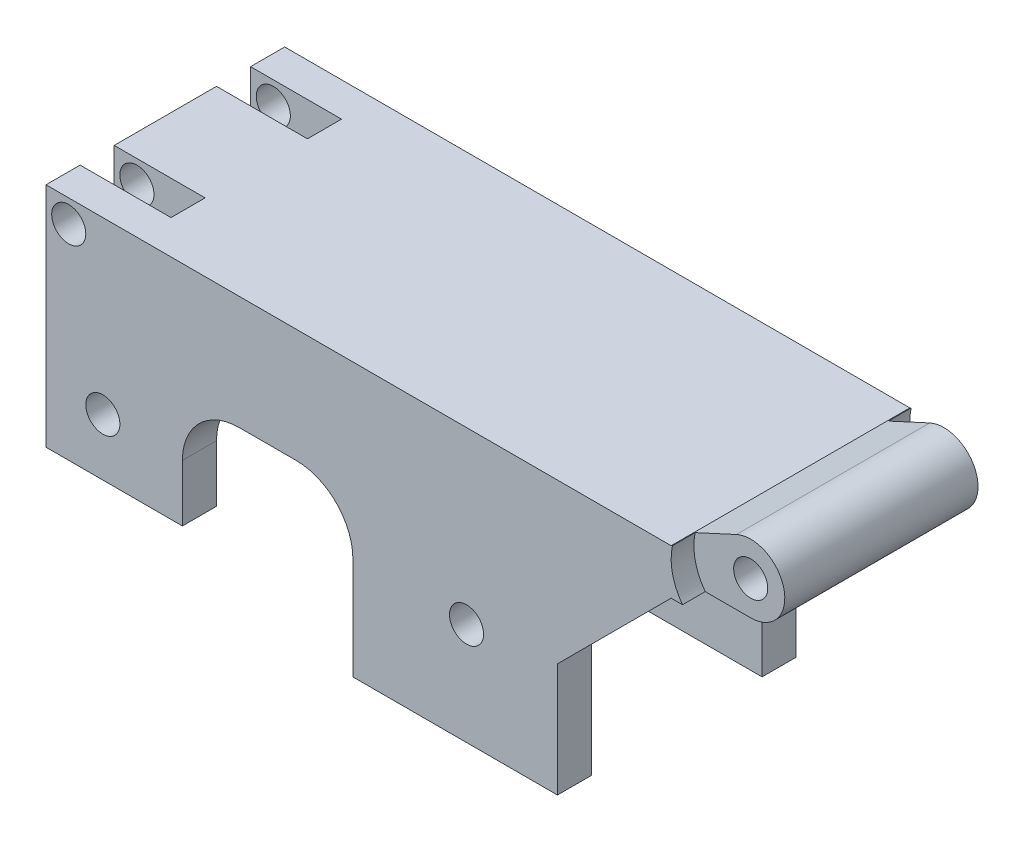
from build123d import *

# Parameters (mm, degrees)
SKETCH_1_R          = 3
SKETCH_1_R_2        = 1.5
EXTRUDE_1_DEPTH     = 25
EXTRUDE_2_DEPTH     = 5
SKETCH_3_R          = 1.5
CUT_EXTRUDE_1_DEPTH = 26
SKETCH_4_R          = 5
CUT_EXTRUDE_2_DEPTH = 4
SKETCH_5_R          = 1.5
EXTRUDE_3_DEPTH     = 5
SKETCH_6_R          = 5
CUT_EXTRUDE_3_DEPTH = 4
SKETCH_7_W          = 8
SKETCH_7_H          = 3
CUT_EXTRUDE_4_DEPTH = 25
SKETCH_8_R          = 1.5
CUT_EXTRUDE_5_DEPTH = 26
SKETCH_9_W          = 62.045271576
SKETCH_9_H          = 47.186533399
CUT_EXTRUDE_6_DEPTH = 2
SKETCH_10_R         = 43.321303534
CUT_EXTRUDE_7_DEPTH = 2


with BuildPart() as part:
    # 草图1 → 凸台-拉伸1 (new body)
    with BuildSketch(Plane.XY):
        with BuildLine():
            Line((-60, -3), (0, -3))
            ThreePointArc((0, -3), (-2.93041003, -0.642415018), (-1.255026274, 2.72486863))
            Line((-1.255026274, 2.72486863), (-5, 1))
            Line((-5, 1), (-60, 1))
            Line((-60, 1), (-60, -3))
        make_face()
        Circle(SKETCH_1_R)
        Circle(SKETCH_1_R_2, mode=Mode.SUBTRACT)
    extrude(amount=EXTRUDE_1_DEPTH)

    # 草图2 → 凸台-拉伸2 (add)
    with BuildSketch(Plane.XY.offset(25)):
        with BuildLine():
            Line((-60, -3), (-60, -19))
            Line((-60, -19), (-48, -19))
            Line((-48, -19), (-48, -14))
            ThreePointArc((-48, -14), (-46.535533906, -10.464466094), (-43, -9))
            Line((-43, -9), (-38, -9))
            ThreePointArc((-38, -9), (-34.464466094, -10.464466094), (-33, -14))
            Line((-33, -14), (-33, -23))
            Line((-33, -23), (-15, -23))
            Line((-15, -23), (-15, -13))
            Line((-15, -13), (-5, -3))
            Line((-5, -3), (-60, -3))
        make_face()
    extrude(amount=-EXTRUDE_2_DEPTH)

    # 草图3 → 切除-拉伸1 (cut, through all)
    with BuildSketch(Plane.XY.offset(25)):
        with Locations((-55, -14)):
            Circle(SKETCH_3_R)
        with Locations((-23, -14)):
            Circle(SKETCH_3_R)
    extrude(amount=-CUT_EXTRUDE_1_DEPTH, mode=Mode.SUBTRACT)

    # 草图4 → 切除-拉伸2 (cut)
    with BuildSketch(Plane.XY.offset(25)):
        Circle(SKETCH_4_R)
    extrude(amount=-CUT_EXTRUDE_2_DEPTH, mode=Mode.SUBTRACT)

    # 草图5 → 凸台-拉伸3 (add)
    with BuildSketch(Plane(origin=(0, 0, 0), x_dir=(-1, 0, 0), z_dir=(0, 0, -1))):
        with BuildLine():
            Line((60, -3), (5, -3))
            Line((5, -3), (15, -13))
            Line((15, -13), (15, -23))
            Line((15, -23), (33, -23))
            Line((33, -23), (33, -14))
            ThreePointArc((33, -14), (34.464466094, -10.464466094), (38, -9))
            Line((38, -9), (43, -9))
            ThreePointArc((43, -9), (46.535533906, -10.464466094), (48, -14))
            Line((48, -14), (48, -19))
            Line((48, -19), (60, -19))
            Line((60, -19), (60, -3))
        make_face()
        with Locations((23, -14)):
            Circle(SKETCH_5_R, mode=Mode.SUBTRACT)
        with Locations((55, -14)):
            Circle(SKETCH_5_R, mode=Mode.SUBTRACT)
    extrude(amount=-EXTRUDE_3_DEPTH)

    # 草图6 → 切除-拉伸3 (cut)
    with BuildSketch(Plane(origin=(0, 0, 0), x_dir=(-1, 0, 0), z_dir=(0, 0, -1))):
        Circle(SKETCH_6_R)
    extrude(amount=-CUT_EXTRUDE_3_DEPTH, mode=Mode.SUBTRACT)

    # 草图7 → 切除-拉伸4 (cut, through all)
    with BuildSketch(Plane(origin=(0, 1, 0), x_dir=(1, 0, 0), z_dir=(0, 1, 0))):
        with Locations((-56, -6.5)):
            Rectangle(SKETCH_7_W, SKETCH_7_H)
        with Locations((-56, -18.5)):
            Rectangle(SKETCH_7_W, SKETCH_7_H)
    extrude(amount=-CUT_EXTRUDE_4_DEPTH, mode=Mode.SUBTRACT)

    # 草图8 → 切除-拉伸5 (cut, through all)
    with BuildSketch(Plane(origin=(0, 0, 0), x_dir=(-1, 0, 0), z_dir=(0, 0, -1))):
        with Locations((58, -1)):
            Circle(SKETCH_8_R)
    extrude(amount=-CUT_EXTRUDE_5_DEPTH, mode=Mode.SUBTRACT)

    # 草图9 → 切除-拉伸6 (cut)
    with BuildSketch(Plane(origin=(0, 0, 0), x_dir=(-1, 0, 0), z_dir=(0, 0, -1))):
        with Locations((33.21865334, -9.347420282)):
            Rectangle(SKETCH_9_W, SKETCH_9_H)
    extrude(amount=-CUT_EXTRUDE_6_DEPTH, mode=Mode.SUBTRACT)

    # 草图10 → 切除-拉伸7 (cut)
    with BuildSketch(Plane.XY.offset(25)):
        with Locations((-29.013307515, -5.864856676)):
            Circle(SKETCH_10_R)
    extrude(amount=-CUT_EXTRUDE_7_DEPTH, mode=Mode.SUBTRACT)


solid = part.part
